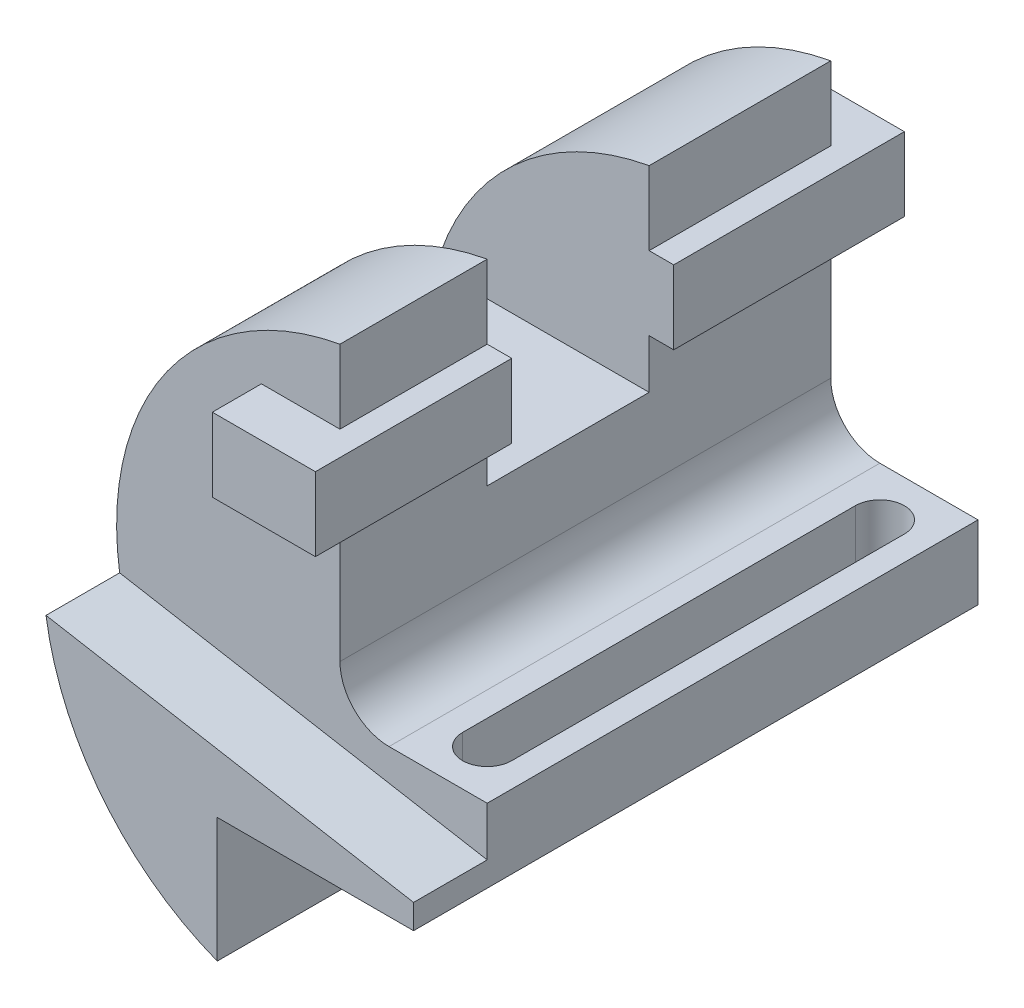
from build123d import *

# Parameters (mm, degrees)
BOSS_EXTRUDE1_DEPTH      = 115
CUT_EXTRUDE1_DEPTH       = 15
SKETCH3_W                = 21
SKETCH3_H                = 15
BOSS_EXTRUDE2_DEPTH      = 10
BOSS_EXTRUDE2_DEPTH_BACK = 110
SKETCH4_W                = 33
SKETCH4_H                = 40
CUT_EXTRUDE2_DEPTH       = 31
CUT_EXTRUDE2_DEPTH_BACK  = 46.5
CUT_EXTRUDE3_DEPTH       = 67
CUT_EXTRUDE3_DEPTH_BACK  = 41.362796982
FILLET1_R                = 10


with BuildPart() as part:
    # Sketch1 → Boss-Extrude1 (new body)
    with BuildSketch(Plane.XY):
        with BuildLine():
            Line((0, 0), (0, 66))
            ThreePointArc((0, 66), (-45.256322222, 16.603413808), (-10, -40.362796982))
            Line((-10, -40.362796982), (-10, -15))
            Line((-10, -15), (30, -15))
            Line((30, -15), (30, 0))
            Line((30, 0), (0, 0))
        make_face()
    extrude(amount=BOSS_EXTRUDE1_DEPTH)

    # Sketch2 → Cut-Extrude1 (cut)
    with BuildSketch(Plane.XY.offset(115)):
        with BuildLine():
            Line((30, -10), (-44.890423857, 3.205202323))
            ThreePointArc((-44.890423857, 3.205202323), (-35.149622711, 43.684665376), (0, 66))
            Line((0, 66), (0, 0))
            Line((0, 0), (30, 0))
            Line((30, 0), (30, -10))
        make_face()
    extrude(amount=-CUT_EXTRUDE1_DEPTH, mode=Mode.SUBTRACT)

    # Sketch3 → Boss-Extrude2 (add, two sides)
    with BuildSketch(Plane(origin=(0, 0, 0), x_dir=(-1, 0, 0), z_dir=(0, 0, -1))) as boss_extrude2_sk:
        with Locations((5.5, 43.5)):
            Rectangle(SKETCH3_W, SKETCH3_H)
    extrude(amount=BOSS_EXTRUDE2_DEPTH)
    extrude(boss_extrude2_sk.sketch, amount=-BOSS_EXTRUDE2_DEPTH_BACK)

    # Sketch4 → Cut-Extrude2 (cut, two sides)
    with BuildSketch(Plane(origin=(0, 0, 0), x_dir=(0, 0, -1), z_dir=(1, 0, 0))) as cut_extrude2_sk:
        with Locations((-53.5, 46)):
            Rectangle(SKETCH4_W, SKETCH4_H)
    extrude(amount=CUT_EXTRUDE2_DEPTH, mode=Mode.SUBTRACT)
    extrude(cut_extrude2_sk.sketch, amount=-CUT_EXTRUDE2_DEPTH_BACK, mode=Mode.SUBTRACT)

    # Sketch5 → Cut-Extrude3 (cut, two sides)
    with BuildSketch(Plane(origin=(0, 0, 0), x_dir=(1, 0, 0), z_dir=(0, 1, 0))) as cut_extrude3_sk:
        with BuildLine():
            Line((25, -10), (25, -90))
            ThreePointArc((25, -90), (20, -95), (15, -90))
            Line((15, -90), (15, -10))
            ThreePointArc((15, -10), (20, -5), (25, -10))
        make_face()
    extrude(amount=CUT_EXTRUDE3_DEPTH, mode=Mode.SUBTRACT)
    extrude(cut_extrude3_sk.sketch, amount=-CUT_EXTRUDE3_DEPTH_BACK, mode=Mode.SUBTRACT)

    # Fillet1
    fillet1_edges = [part.edges().sort_by_distance(p)[0] for p in [
        (0, 0, 50),
    ]]
    fillet(fillet1_edges, radius=FILLET1_R)


solid = part.part
